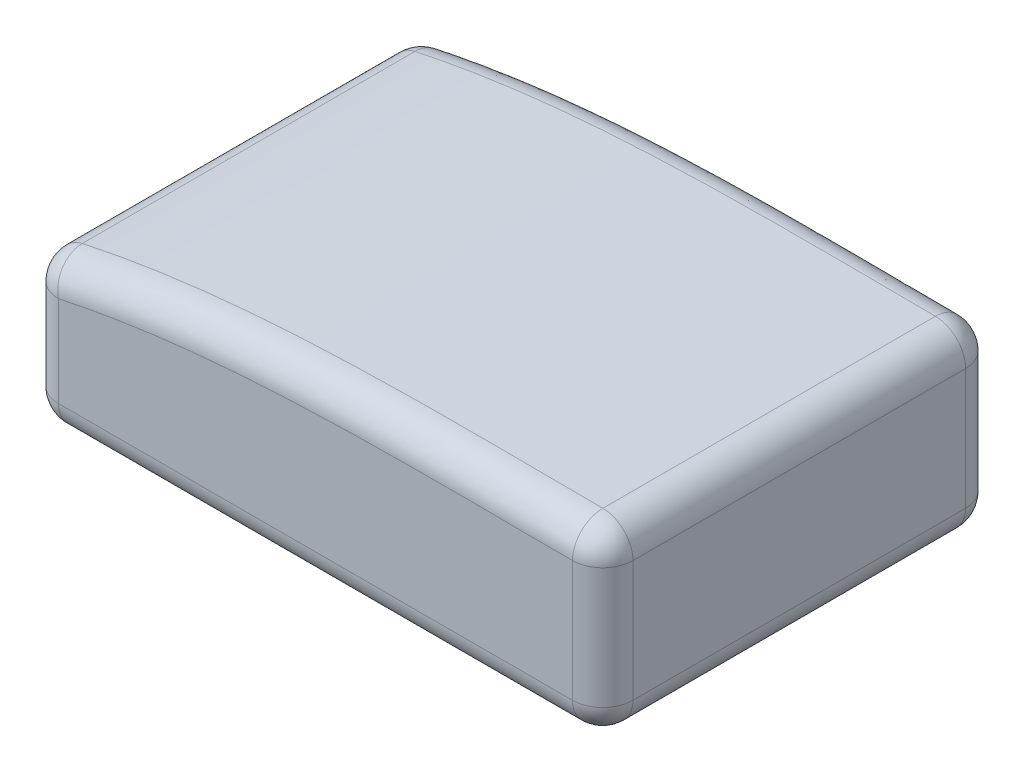
from build123d import *

# Parameters (mm, degrees)
BOSS_EXTRUDE1_DEPTH = 65
FILLET1_R           = 5


with BuildPart() as part:
    # Sketch1 → Boss-Extrude1 (new body)
    with BuildSketch(Plane.XY):
        with BuildLine():
            Line((-42.5, -17), (42.5, -17))
            ThreePointArc((42.5, -17), (46.035533906, -15.535533906), (47.5, -12))
            Line((47.5, -12), (47.5, 8.010433268))
            ThreePointArc((47.5, 8.010433268), (46.0423765, 11.539111311), (42.519372507, 13.010395738))
            add(Edge.make_bspline(
                [(-43.555532841, 7.899733163), (-30.176694997, 10.789213784), (-1.352486938, 13.578958487), (27.425027944, 13.068879237), (42.519372507, 13.010395738)],
                knots=[0.042375719, 0.042375719, 0.042375719, 0.042375719, 0.472818051, 0.947722656, 0.947722656, 0.947722656, 0.947722656], degree=3))
            ThreePointArc((-43.555532841, 7.899733163), (-46.390865213, 6.152667561), (-47.5, 3.012417906))
            Line((-47.5, 3.012417906), (-47.5, -12))
            ThreePointArc((-47.5, -12), (-46.035533906, -15.535533906), (-42.5, -17))
        make_face()
    extrude(amount=BOSS_EXTRUDE1_DEPTH)

    # Fillet1
    fillet1_edges = [part.edges().sort_by_distance(p)[0] for p in [
        (-47.5, -4.493791047, 65),
        (-46.390865213, 6.152667561, 0),
        (-0.682392831, 12.779176888, 0),
        (-46.035533906, -15.535533906, 65),
        (0, -17, 65),
        (46.035533906, -15.535533906, 65),
        (47.5, -1.994783366, 65),
        (46.0423765, 11.539111311, 65),
        (-0.682392831, 12.779176888, 65),
        (-46.390865213, 6.152667561, 65),
        (46.0423765, 11.539111311, 0),
        (47.5, -1.994783366, 0),
        (46.035533906, -15.535533906, 0),
        (0, -17, 0),
        (-46.035533906, -15.535533906, 0),
        (-47.5, -4.493791047, 0),
    ]]
    fillet(fillet1_edges, radius=FILLET1_R)


solid = part.part
